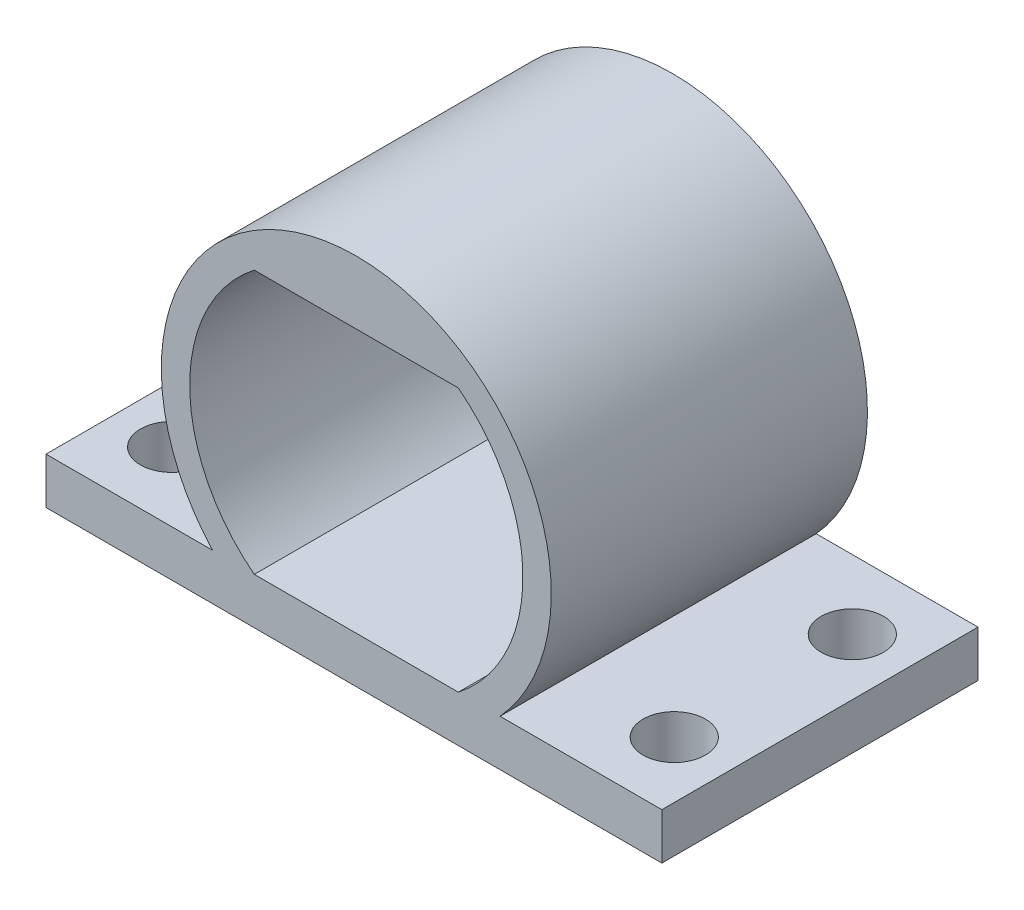
from build123d import *

# Parameters (mm, degrees)
BOSS_EXTRUDE1_DEPTH = 12
SKETCH3_R           = 1.184698277
CUT_EXTRUDE3_DEPTH  = 5
BOSS_EXTRUDE6_DEPTH = 12
CUT_EXTRUDE4_DEPTH  = 12
SKETCH10_R          = 1.184698277
CUT_EXTRUDE5_DEPTH  = 12
CUT_EXTRUDE7_DEPTH  = 19


with BuildPart() as part:
    # Sketch1 → Boss-Extrude1 (new body)
    with BuildSketch(Plane.XY):
        with BuildLine():
            Line((-4.775747962, -5), (-3.406624892, -5))
            ThreePointArc((-3.406624892, -5), (-6.090000101, 0), (-3.406624892, 5))
            Line((-3.406624892, 5), (3.226624689, 5))
            ThreePointArc((3.226624689, 5), (5.909999899, 0), (3.226624689, -5))
            Line((3.226624689, -5), (4.595747759, -5))
            ThreePointArc((4.595747759, -5), (-0.090000101, 6.852461821), (-4.775747962, -5))
        make_face()
        with BuildLine():
            Line((11.597073435, -5), (4.595747759, -5))
            ThreePointArc((4.595747759, -5), (3.939029098, -5.542847348), (3.220019991, -6))
            Line((3.220019991, -6), (11.597073435, -6))
            Line((11.597073435, -6), (11.597073435, -5))
        make_face()
        with BuildLine():
            Line((3.226624689, -5), (-3.406624892, -5))
            Line((-3.406624892, -5), (-4.775747962, -5))
            ThreePointArc((-4.775747962, -5), (-4.119029301, -5.542847348), (-3.400020194, -6))
            Line((-3.400020194, -6), (3.220019991, -6))
            ThreePointArc((3.220019991, -6), (3.939029098, -5.542847348), (4.595747759, -5))
            Line((4.595747759, -5), (3.226624689, -5))
        make_face()
        with BuildLine():
            ThreePointArc((-3.400020194, -6), (-4.119029301, -5.542847348), (-4.775747962, -5))
            Line((-4.775747962, -5), (-11.777073637, -5))
            Line((-11.777073637, -5), (-11.777073637, -6))
            Line((-11.777073637, -6), (-3.400020194, -6))
        make_face()
    extrude(amount=BOSS_EXTRUDE1_DEPTH)

    # Sketch3 → Cut-Extrude3 (cut)
    with BuildSketch(Plane(origin=(0, -5, 0), x_dir=(1, 0, 0), z_dir=(0, 1, 0))):
        with Locations((-9.627163284, -9.379788166)):
            Circle(SKETCH3_R)
        with Locations((9.447163082, -9.379788166)):
            Circle(SKETCH3_R)
        with Locations((9.447163082, -2.620211834)):
            Circle(SKETCH3_R)
        with Locations((-9.627163284, -2.620211834)):
            Circle(SKETCH3_R)
    extrude(amount=-CUT_EXTRUDE3_DEPTH, mode=Mode.SUBTRACT)

    # Sketch7 → Boss-Extrude6 (add)
    with BuildSketch(Plane.XY.offset(12)):
        with BuildLine():
            ThreePointArc((5.456145908, -5), (0, 7.400643767), (-5.456145908, -5))
            Line((-5.456145908, -5), (-4.775747962, -5))
            ThreePointArc((-4.775747962, -5), (-0.090000101, 6.852461821), (4.595747759, -5))
            Line((4.595747759, -5), (5.456145908, -5))
        make_face()
        with BuildLine():
            Line((-4.33238135, -6), (-11.777073637, -6))
            Line((-11.777073637, -6), (-11.777073637, -6.756480667))
            Line((-11.777073637, -6.756480667), (-3.019850519, -6.756480667))
            ThreePointArc((-3.019850519, -6.756480667), (-3.695523524, -6.411913447), (-4.33238135, -6))
        make_face()
        with BuildLine():
            Line((4.33238135, -6), (-4.33238135, -6))
            ThreePointArc((-4.33238135, -6), (-3.695523524, -6.411913447), (-3.019850519, -6.756480667))
            Line((-3.019850519, -6.756480667), (3.019850519, -6.756480667))
            ThreePointArc((3.019850519, -6.756480667), (3.695523524, -6.411913447), (4.33238135, -6))
        make_face()
        with BuildLine():
            Line((11.597073435, -6), (4.33238135, -6))
            ThreePointArc((4.33238135, -6), (3.695523524, -6.411913447), (3.019850519, -6.756480667))
            Line((3.019850519, -6.756480667), (11.597073435, -6.756480667))
            Line((11.597073435, -6.756480667), (11.597073435, -6))
        make_face()
    extrude(amount=-BOSS_EXTRUDE6_DEPTH)

    # Sketch9 → Cut-Extrude4 (cut)
    with BuildSketch(Plane.XY.offset(12)):
        with BuildLine():
            Line((-3.476794678, 5), (3.476794678, 5))
            ThreePointArc((3.476794678, 5), (6.090000101, 0), (3.476794678, -5))
            Line((3.476794678, -5), (-3.476794678, -5))
            ThreePointArc((-3.476794678, -5), (-6.090000101, 0), (-3.476794678, 5))
        make_face()
    extrude(amount=-CUT_EXTRUDE4_DEPTH, mode=Mode.SUBTRACT)

    # Sketch10 → Cut-Extrude5 (cut)
    with BuildSketch(Plane(origin=(0, -5, 0), x_dir=(1, 0, 0), z_dir=(0, 1, 0))):
        with Locations((-9.627163284, -2.620211834)):
            Circle(SKETCH10_R)
        with Locations((-9.627163284, -9.379788166)):
            Circle(SKETCH10_R)
        with Locations((9.447163082, -2.620211834)):
            Circle(SKETCH10_R)
        with Locations((9.447163082, -9.379788166)):
            Circle(SKETCH10_R)
    extrude(amount=-CUT_EXTRUDE5_DEPTH, mode=Mode.SUBTRACT)

    # Sketch11 → Cut-Extrude7 (cut)
    with BuildSketch(Plane.XY.offset(12)):
        with BuildLine():
            Line((-3.476794678, 5), (-3.871774203, 5))
            ThreePointArc((-3.871774203, 5), (-6.323814947, 0), (-3.871774203, -5))
            Line((-3.871774203, -5), (-3.476794678, -5))
            Line((-3.476794678, -5), (3.871774203, -5))
            ThreePointArc((3.871774203, -5), (6.323814947, 0), (3.871774203, 5))
            Line((3.871774203, 5), (-3.476794678, 5))
        make_face()
    extrude(amount=-CUT_EXTRUDE7_DEPTH, mode=Mode.SUBTRACT)


solid = part.part
